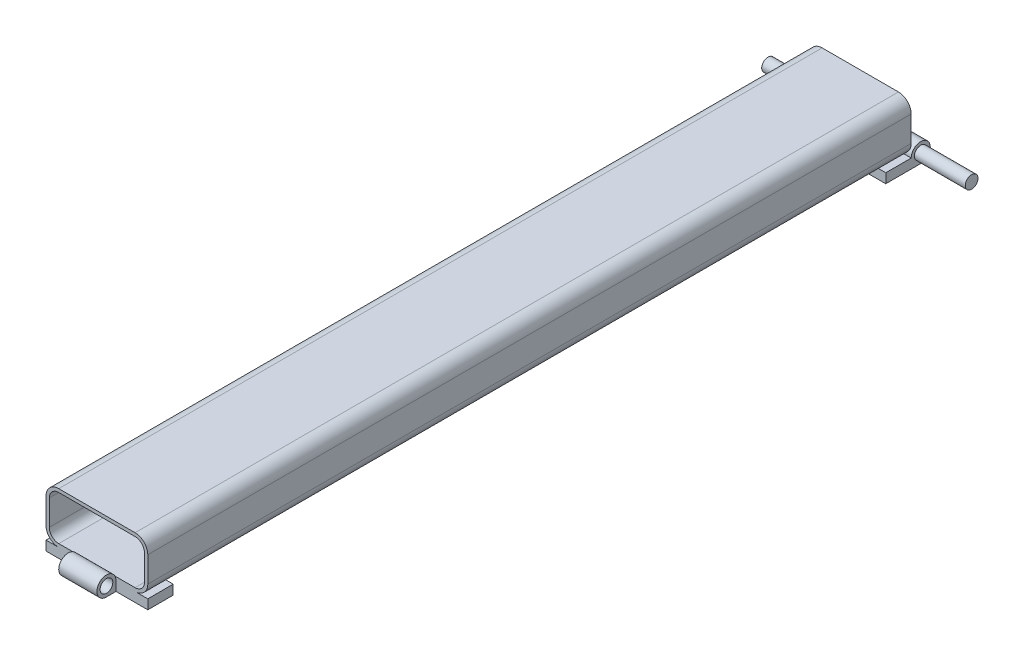
from build123d import *

# Parameters (mm, degrees)
BOSS_EXTRUDE1_DEPTH = 190.5
BOSS_EXTRUDE2_DEPTH = 50.8
SKETCH3_R           = 3.175
BOSS_EXTRUDE3_DEPTH = 50.8
SKETCH4_W           = 15.875
SKETCH4_H           = 9.525
CUT_EXTRUDE1_DEPTH  = 31.1625
SKETCH5_R           = 3.175
CUT_EXTRUDE2_DEPTH  = 61.325


with BuildPart() as part:
    # Sketch1 → Boss-Extrude1 (new body, symmetric)
    with BuildSketch(Plane.XY):
        with BuildLine():
            Line((-19.05, -12.7), (19.05, -12.7))
            ThreePointArc((19.05, -12.7), (23.540128061, -10.840128061), (25.4, -6.35))
            Line((25.4, -6.35), (25.4, 6.35))
            ThreePointArc((25.4, 6.35), (23.540128061, 10.840128061), (19.05, 12.7))
            Line((19.05, 12.7), (-19.05, 12.7))
            ThreePointArc((-19.05, 12.7), (-23.540128061, 10.840128061), (-25.4, 6.35))
            Line((-25.4, 6.35), (-25.4, -6.35))
            ThreePointArc((-25.4, -6.35), (-23.540128061, -10.840128061), (-19.05, -12.7))
        make_face()
        with BuildLine():
            Line((-19.05, 11.049), (19.05, 11.049))
            ThreePointArc((19.05, 11.049), (22.372694765, 9.672694765), (23.749, 6.35))
            Line((23.749, 6.35), (23.749, -6.35))
            ThreePointArc((23.749, -6.35), (22.372694765, -9.672694765), (19.05, -11.049))
            Line((19.05, -11.049), (-19.05, -11.049))
            ThreePointArc((-19.05, -11.049), (-22.372694765, -9.672694765), (-23.749, -6.35))
            Line((-23.749, -6.35), (-23.749, 6.35))
            ThreePointArc((-23.749, 6.35), (-22.372694765, 9.672694765), (-19.05, 11.049))
        make_face(mode=Mode.SUBTRACT)
    extrude(amount=BOSS_EXTRUDE1_DEPTH, both=True)

    # Sketch2 → Boss-Extrude2 (add, through all)
    with BuildSketch(Plane(origin=(25.4, 0, 0), x_dir=(0, 0, -1), z_dir=(1, 0, 0))):
        with BuildLine():
            Line((177.8, -12.7), (177.8, -17.4625))
            Line((177.8, -17.4625), (195.2625, -17.4625))
            ThreePointArc((195.2625, -17.4625), (198.630096045, -9.332403955), (190.5, -12.7))
            Line((190.5, -12.7), (177.8, -12.7))
        make_face()
    boss_extrude2 = extrude(amount=-BOSS_EXTRUDE2_DEPTH)

    # Mirror1: Boss-Extrude2 across plane
    add(boss_extrude2.mirror(Plane.XY))

    # Sketch3 → Boss-Extrude3 (add, symmetric)
    with BuildSketch(Plane(origin=(0, 0, 0), x_dir=(0, 0, -1), z_dir=(1, 0, 0))):
        with Locations((195.2625, -12.7)):
            Circle(SKETCH3_R)
    extrude(amount=BOSS_EXTRUDE3_DEPTH, both=True)

    # Sketch4 → Cut-Extrude1 (cut, through all)
    with BuildSketch(Plane.XZ.offset(17.4625)):
        with Locations((-17.4625, 195.2625)):
            Rectangle(SKETCH4_W, SKETCH4_H)
        with Locations((17.4625, 195.2625)):
            Rectangle(SKETCH4_W, SKETCH4_H)
    extrude(amount=-CUT_EXTRUDE1_DEPTH, mode=Mode.SUBTRACT)

    # Sketch5 → Cut-Extrude2 (cut, through all)
    with BuildSketch(Plane(origin=(9.525, 0, 0), x_dir=(0, 0, -1), z_dir=(1, 0, 0))):
        with Locations((-195.2625, -12.7)):
            Circle(SKETCH5_R)
    extrude(amount=-CUT_EXTRUDE2_DEPTH, mode=Mode.SUBTRACT)


solid = part.part
